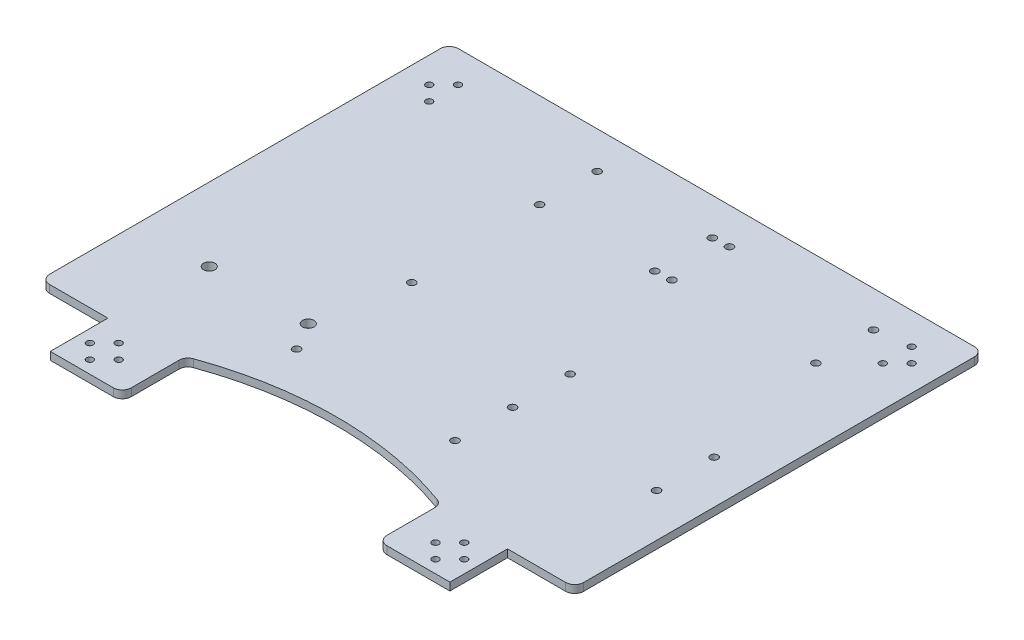
from build123d import *

# Parameters (mm, degrees)
SKETCH1_R           = 1.85
SKETCH1_R_2         = 2.1
SKETCH1_R_3         = 3.175
BOSS_EXTRUDE1_DEPTH = 4.3


with BuildPart() as part:
    # Sketch1 → Boss-Extrude1 (new body)
    with BuildSketch(Plane(origin=(0, 0, 0), x_dir=(1, 0, 0), z_dir=(0, 1, 0))):
        with BuildLine():
            Line((-143.318, 44.044009042), (143.318, 44.044009042))
            ThreePointArc((143.318, 44.044009042), (146.853533906, 42.579542947), (148.318, 39.044009042))
            Line((148.318, 39.044009042), (148.318, -177.955990958))
            ThreePointArc((148.318, -177.955990958), (146.853533906, -181.491524864), (143.318, -182.955990958))
            Line((143.318, -182.955990958), (111, -182.955990958))
            Line((111, -182.955990958), (111, -214.955990958))
            Line((111, -214.955990958), (76, -214.955990958))
            ThreePointArc((76, -214.955990958), (72.464466094, -213.491524864), (71, -209.955990958))
            Line((71, -209.955990958), (71, -183.438106878))
            ThreePointArc((71, -183.438106878), (70.090326299, -180.562479856), (67.692307692, -178.733205745))
            ThreePointArc((67.692307692, -178.733205745), (0, -166.929251079), (-67.692307692, -178.733205745))
            ThreePointArc((-67.692307692, -178.733205745), (-70.090326299, -180.562479856), (-71, -183.438106878))
            Line((-71, -183.438106878), (-71, -209.955990958))
            ThreePointArc((-71, -209.955990958), (-72.464466094, -213.491524864), (-76, -214.955990958))
            Line((-76, -214.955990958), (-111, -214.955990958))
            Line((-111, -214.955990958), (-111, -182.955990958))
            Line((-111, -182.955990958), (-143.318, -182.955990958))
            ThreePointArc((-143.318, -182.955990958), (-146.853533906, -181.491524864), (-148.318, -177.955990958))
            Line((-148.318, -177.955990958), (-148.318, 39.044009042))
            ThreePointArc((-148.318, 39.044009042), (-146.853533906, 42.579542947), (-143.318, 44.044009042))
        make_face()
        with Locations((126, 26.544009042)):
            Circle(SKETCH1_R, mode=Mode.SUBTRACT)
        with Locations((134, 18.544009042)):
            Circle(SKETCH1_R, mode=Mode.SUBTRACT)
        with Locations((126, 10.544009042)):
            Circle(SKETCH1_R, mode=Mode.SUBTRACT)
        with Locations((107.318, -7.955990958)):
            Circle(SKETCH1_R_2, mode=Mode.SUBTRACT)
        with Locations((107.318, 24.044009042)):
            Circle(SKETCH1_R_2, mode=Mode.SUBTRACT)
        with Locations((18.318, 23.544009041)):
            Circle(SKETCH1_R_2, mode=Mode.SUBTRACT)
        with Locations((27.318, 24.044009042)):
            Circle(SKETCH1_R_2, mode=Mode.SUBTRACT)
        with Locations((18.318, -8.455990959)):
            Circle(SKETCH1_R_2, mode=Mode.SUBTRACT)
        with Locations((27.318, -7.955990958)):
            Circle(SKETCH1_R_2, mode=Mode.SUBTRACT)
        with Locations((-134, 18.544009042)):
            Circle(SKETCH1_R, mode=Mode.SUBTRACT)
        with Locations((-126, 10.544009042)):
            Circle(SKETCH1_R, mode=Mode.SUBTRACT)
        with Locations((-126, 26.544009042)):
            Circle(SKETCH1_R, mode=Mode.SUBTRACT)
        with Locations((-45.682, -8.455990959)):
            Circle(SKETCH1_R_2, mode=Mode.SUBTRACT)
        with Locations((-45.682, 23.544009041)):
            Circle(SKETCH1_R_2, mode=Mode.SUBTRACT)
        with Locations((-43.68216529, -145.455990959)):
            Circle(SKETCH1_R_2, mode=Mode.SUBTRACT)
        with Locations((-43.68216529, -81.455495942)):
            Circle(SKETCH1_R_2, mode=Mode.SUBTRACT)
        with Locations((44.318, -145.455990959)):
            Circle(SKETCH1_R_2, mode=Mode.SUBTRACT)
        with Locations((44.318, -113.455990958)):
            Circle(SKETCH1_R_2, mode=Mode.SUBTRACT)
        with Locations((44.318, -81.455495942)):
            Circle(SKETCH1_R_2, mode=Mode.SUBTRACT)
        with Locations((-96, -191.955990958)):
            Circle(SKETCH1_R, mode=Mode.SUBTRACT)
        with Locations((-104, -199.955990958)):
            Circle(SKETCH1_R, mode=Mode.SUBTRACT)
        with Locations((-88, -199.955990958)):
            Circle(SKETCH1_R, mode=Mode.SUBTRACT)
        with Locations((-96, -207.955990958)):
            Circle(SKETCH1_R, mode=Mode.SUBTRACT)
        with Locations((96, -207.955990958)):
            Circle(SKETCH1_R, mode=Mode.SUBTRACT)
        with Locations((96, -191.955990958)):
            Circle(SKETCH1_R, mode=Mode.SUBTRACT)
        with Locations((104, -199.955990958)):
            Circle(SKETCH1_R, mode=Mode.SUBTRACT)
        with Locations((88, -199.955990958)):
            Circle(SKETCH1_R, mode=Mode.SUBTRACT)
        with Locations((124.318, -81.455495942)):
            Circle(SKETCH1_R_2, mode=Mode.SUBTRACT)
        with Locations((124.318, -113.455495942)):
            Circle(SKETCH1_R_2, mode=Mode.SUBTRACT)
        with Locations((-52.68216529, -129.955990958)):
            Circle(SKETCH1_R_3, mode=Mode.SUBTRACT)
        with Locations((-107.68216529, -129.955990958)):
            Circle(SKETCH1_R_3, mode=Mode.SUBTRACT)
    extrude(amount=BOSS_EXTRUDE1_DEPTH)


solid = part.part
